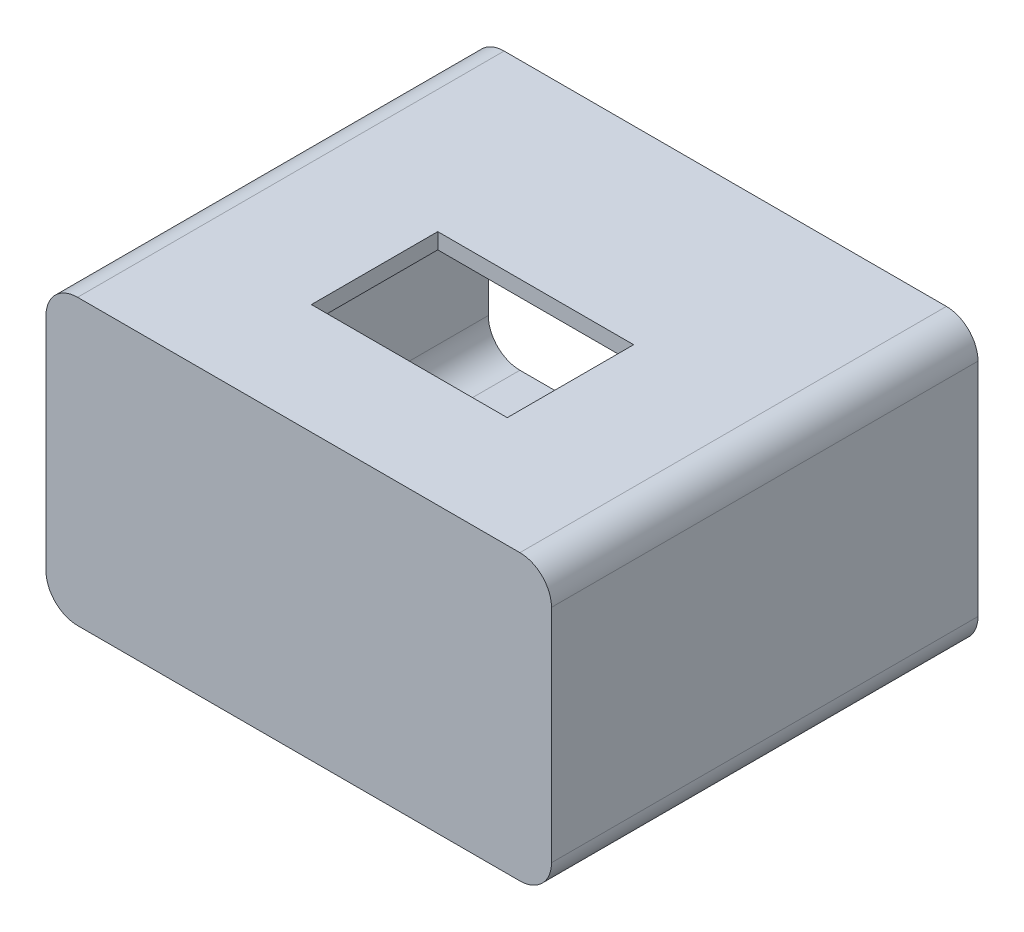
from build123d import *

# Parameters (mm, degrees)
BOSS_EXTRUDE1_DEPTH = 65
BOSS_EXTRUDE2_DEPTH = 2.5
CUT_EXTRUDE1_REACH  = 47
SKETCH4_W           = 31
SKETCH4_H           = 20


with BuildPart() as part:
    # Sketch2 → Boss-Extrude1 (new body)
    with BuildSketch(Plane.XY):
        with BuildLine():
            ThreePointArc((-40, 17.5), (-38.535533906, 21.035533906), (-35, 22.5))
            Line((-35, 22.5), (35, 22.5))
            ThreePointArc((35, 22.5), (38.535533906, 21.035533906), (40, 17.5))
            Line((40, 17.5), (40, -17.5))
            ThreePointArc((40, -17.5), (38.535533906, -21.035533906), (35, -22.5))
            Line((35, -22.5), (-35, -22.5))
            ThreePointArc((-35, -22.5), (-38.535533906, -21.035533906), (-40, -17.5))
            Line((-40, -17.5), (-40, 17.5))
        make_face()
        with BuildLine():
            ThreePointArc((-32.5, 20), (-36.035533906, 18.535533906), (-37.5, 15))
            Line((-37.5, 15), (-37.5, -15))
            ThreePointArc((-37.5, -15), (-36.035533906, -18.535533906), (-32.5, -20))
            Line((-32.5, -20), (32.5, -20))
            ThreePointArc((32.5, -20), (36.035533906, -18.535533906), (37.5, -15))
            Line((37.5, -15), (37.5, 15))
            ThreePointArc((37.5, 15), (36.035533906, 18.535533906), (32.5, 20))
            Line((32.5, 20), (-32.5, 20))
        make_face(mode=Mode.SUBTRACT)
    extrude(amount=BOSS_EXTRUDE1_DEPTH)

    # Sketch3 → Boss-Extrude2 (add)
    with BuildSketch(Plane.XY.offset(65)):
        with BuildLine():
            Line((-40, 17.5), (-40, -17.5))
            ThreePointArc((-40, -17.5), (-38.535533906, -21.035533906), (-35, -22.5))
            Line((-35, -22.5), (35, -22.5))
            ThreePointArc((35, -22.5), (38.535533906, -21.035533906), (40, -17.5))
            Line((40, -17.5), (40, 17.5))
            ThreePointArc((40, 17.5), (38.535533906, 21.035533906), (35, 22.5))
            Line((35, 22.5), (-35, 22.5))
            ThreePointArc((-35, 22.5), (-38.535533906, 21.035533906), (-40, 17.5))
        make_face()
    extrude(amount=BOSS_EXTRUDE2_DEPTH)

    # Sketch4 → Cut-Extrude1 (cut, up to next)
    with BuildSketch(Plane(origin=(0, 22.5, 0), x_dir=(1, 0, 0), z_dir=(0, 1, 0)), mode=Mode.PRIVATE) as cut_extrude1_sk1:
        with Locations((0, -40)):
            Rectangle(SKETCH4_W, SKETCH4_H)
    cut_extrude1_tool1 = extrude(cut_extrude1_sk1.sketch, amount=-CUT_EXTRUDE1_REACH, mode=Mode.PRIVATE) & part.part
    add(cut_extrude1_tool1.solids().sort_by_distance((0, 22.5, 40))[0], mode=Mode.SUBTRACT)


solid = part.part
